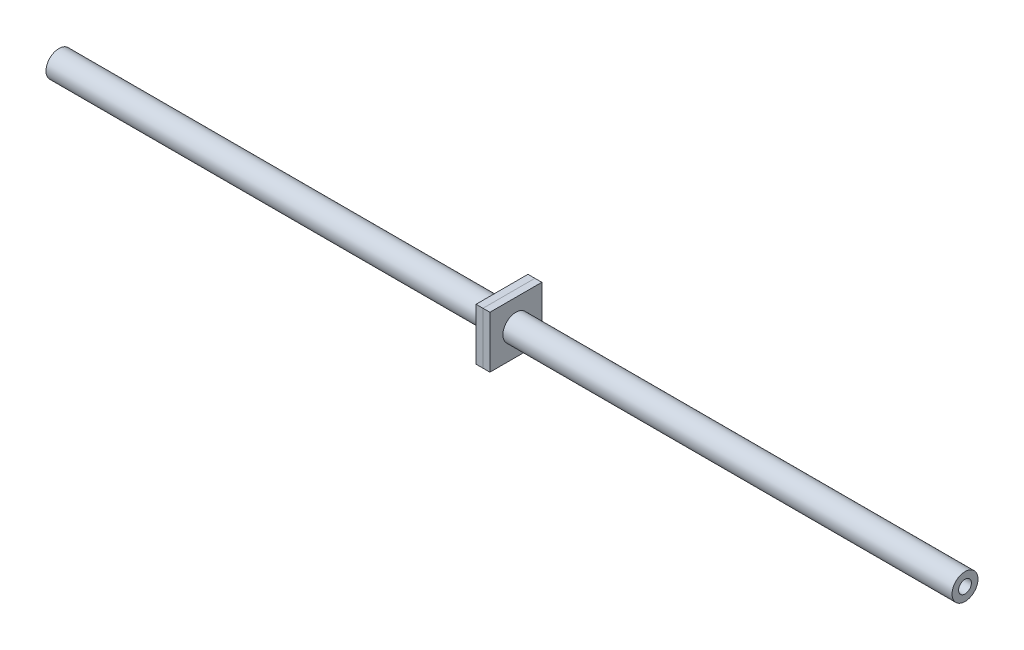
from build123d import *

# Parameters (mm, degrees)
SKETCH1_R            = 4.7625
SKETCH1_R_2          = 2.3495
TOE_ROD_MEMBER_DEPTH = 332.4405
TOE_START            = 165.1
SKETCH2_W            = 19.05
SKETCH2_H            = 19.05
SKETCH2_R            = 4.7625
TOE_ROD_NUT_1_DEPTH  = 2.54
SKETCH3_W            = 19.05
SKETCH3_H            = 19.05
SKETCH3_R            = 4.7625
TOE_ROD_NUT_2_DEPTH  = 2.54


with BuildPart() as part:
    # Sketch1 → Toe Rod Member (new body)
    with BuildSketch(Plane.YZ):
        Circle(SKETCH1_R)
        Circle(SKETCH1_R_2, mode=Mode.SUBTRACT)
    extrude(amount=TOE_ROD_MEMBER_DEPTH)


with BuildPart() as body_2:
    # Sketch2 → Toe Rod Nut 1 (new body)
    with BuildSketch(Plane(origin=(0, 0, 0), x_dir=(0, 0, -1), z_dir=(1, 0, 0)).offset(TOE_START)):
        Rectangle(SKETCH2_W, SKETCH2_H)
        Circle(SKETCH2_R, mode=Mode.SUBTRACT)
    extrude(amount=TOE_ROD_NUT_1_DEPTH)


with BuildPart() as body_3:
    # Sketch3 → Toe Rod Nut 2 (new body)
    with BuildSketch(Plane(origin=(0, 0, 0), x_dir=(0, 0, -1), z_dir=(1, 0, 0)).offset(TOE_START)):
        Rectangle(SKETCH3_W, SKETCH3_H)
        with Locations(Location((0, 0, 0), (0, 0, 180))):
            Circle(SKETCH3_R, mode=Mode.SUBTRACT)
    extrude(amount=-TOE_ROD_NUT_2_DEPTH)


solid = Compound([part.part, body_2.part, body_3.part])
